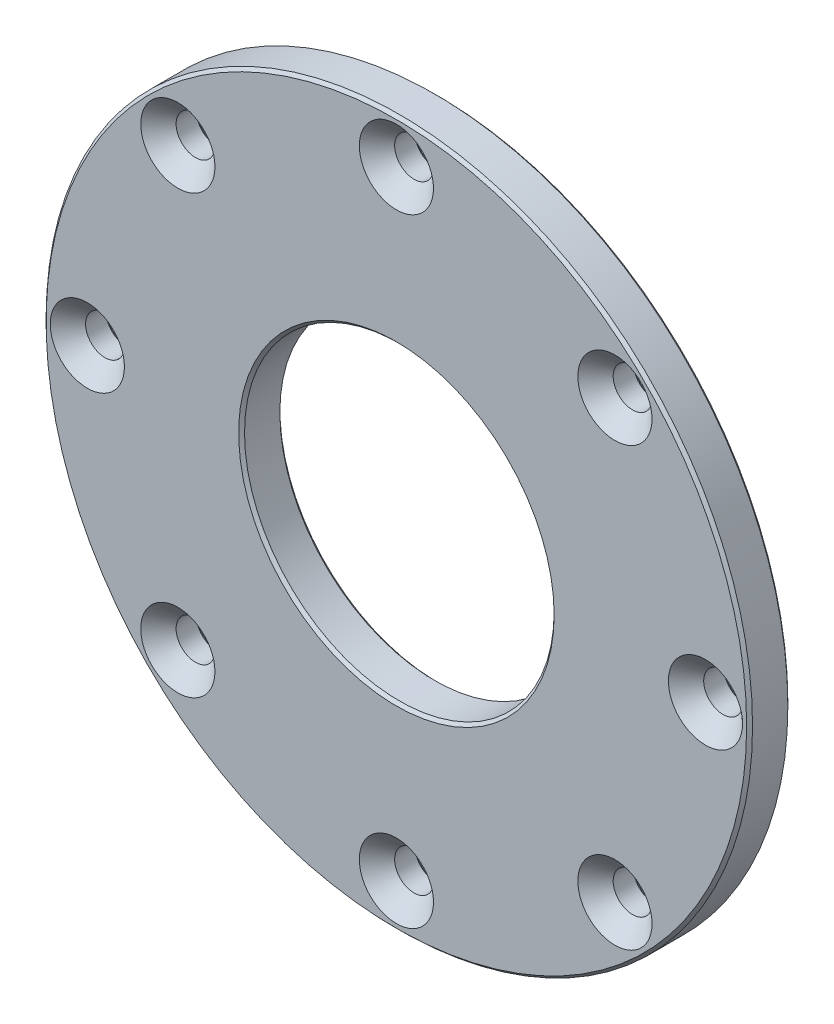
from build123d import *

# Parameters (mm, degrees)
SKETCH1_R                                           = 60
SKETCH1_R_2                                         = 26.3
BOSS_EXTRUDE1_DEPTH                                 = 7
CSK_FOR_M6_COUNTERSUNK_FLAT_HEAD_SCREW1_D           = 6.6
CSK_FOR_M6_COUNTERSUNK_FLAT_HEAD_SCREW1_CSINK_D     = 12.6
CSK_FOR_M6_COUNTERSUNK_FLAT_HEAD_SCREW1_CSINK_ANGLE = 90
CHAMFER1_SIZE                                       = 0.5


with BuildPart() as part:
    # Sketch1 → Boss-Extrude1 (new body)
    with BuildSketch(Plane.XY):
        Circle(SKETCH1_R)
        Circle(SKETCH1_R_2, mode=Mode.SUBTRACT)
    extrude(amount=BOSS_EXTRUDE1_DEPTH)

    # CSK for M6 Countersunk Flat Head Screw1 (through all)
    with Locations(Plane.XY.offset(7)):
        with Locations((-37.123106012, 37.123106012), (0, 52.5), (37.123106012, 37.123106012), (52.5, 0), (37.123106012, -37.123106012), (0, -52.5), (-37.123106012, -37.123106012), (-52.5, 0)):
            CounterSinkHole(CSK_FOR_M6_COUNTERSUNK_FLAT_HEAD_SCREW1_D / 2, CSK_FOR_M6_COUNTERSUNK_FLAT_HEAD_SCREW1_CSINK_D / 2, counter_sink_angle=CSK_FOR_M6_COUNTERSUNK_FLAT_HEAD_SCREW1_CSINK_ANGLE)

    # Chamfer1
    chamfer1_edges = [part.edges().sort_by_distance(p)[0] for p in [
        (-33.823106012, 37.123106012, 0),
        (-60, 0, 0),
        (-49.2, 0, 0),
        (-33.823106012, -37.123106012, 0),
        (3.3, -52.5, 0),
        (40.423106012, -37.123106012, 0),
        (55.8, 0, 0),
        (-60, 0, 7),
        (-26.3, 0, 0),
        (40.423106012, 37.123106012, 0),
        (-26.3, 0, 7),
        (3.3, 52.5, 0),
    ]]
    chamfer(chamfer1_edges, length=CHAMFER1_SIZE)


solid = part.part
